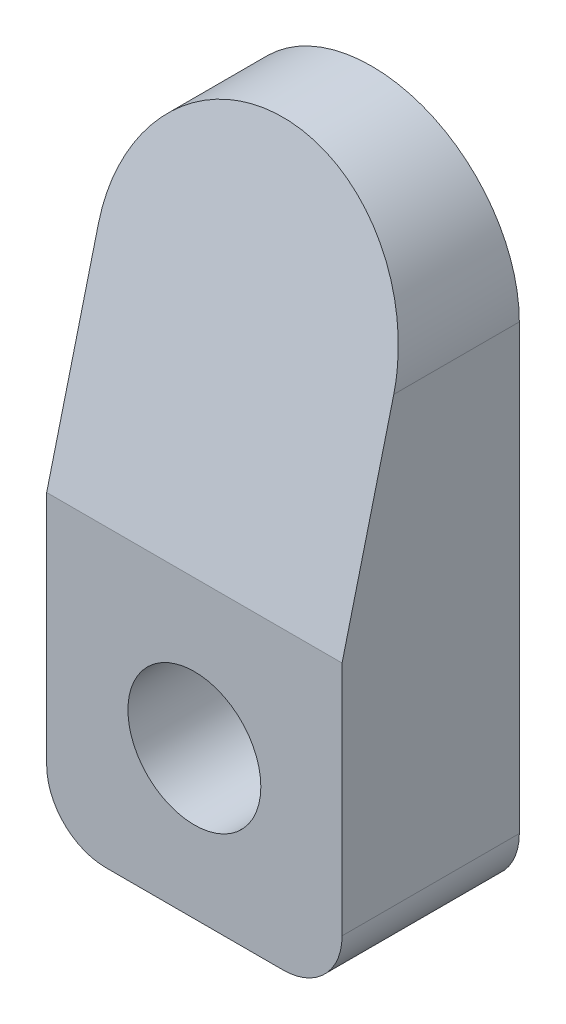
from build123d import *

# Parameters (mm, degrees)
SKETCH1_R           = 2.25
BOSS_EXTRUDE1_DEPTH = 6
CUT_EXTRUDE1_DEPTH  = 11
FILLET1_R           = 2


with BuildPart() as part:
    # Sketch1 → Boss-Extrude1 (new body)
    with BuildSketch(Plane.XY):
        with BuildLine():
            Line((-5, 12), (-5, -5))
            Line((-5, -5), (5, -5))
            Line((5, -5), (5, 12))
            ThreePointArc((5, 12), (0, 17), (-5, 12))
        make_face()
        Circle(SKETCH1_R, mode=Mode.SUBTRACT)
    extrude(amount=BOSS_EXTRUDE1_DEPTH)

    # Sketch2 → Cut-Extrude1 (cut, through all)
    with BuildSketch(Plane(origin=(5, 0, 0), x_dir=(0, 0, -1), z_dir=(1, 0, 0))):
        Polygon((-6, 5), (-3, 17), (-6, 17), align=None)
    extrude(amount=-CUT_EXTRUDE1_DEPTH, mode=Mode.SUBTRACT)

    # Fillet1
    fillet1_edges = [part.edges().sort_by_distance(p)[0] for p in [
        (5, -5, 3),
        (-5, -5, 3),
    ]]
    fillet(fillet1_edges, radius=FILLET1_R)


solid = part.part
